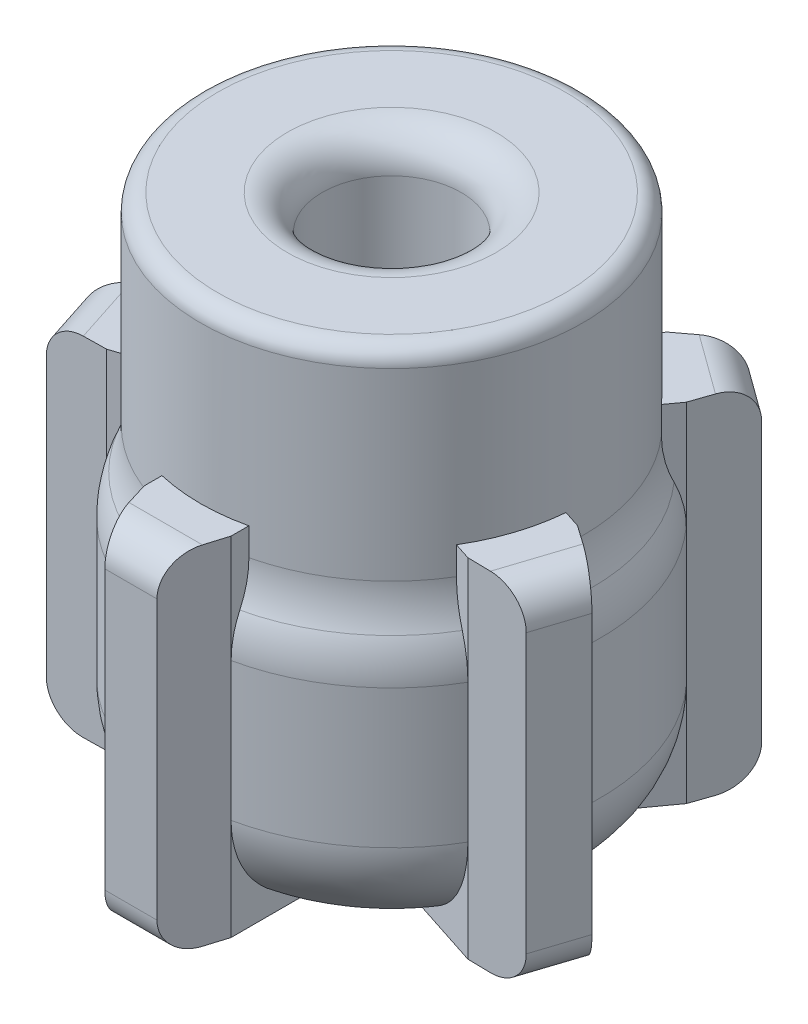
from build123d import *

# Parameters (mm, degrees)
SKETCH3_R           = 4
CUT_EXTRUDE2_DEPTH  = 29
FILLET2_R           = 2
BOSS_EXTRUDE1_DEPTH = 20
FILLET3_R           = 2


with BuildPart() as part:
    # Sketch1 → Revolve1 (revolve)
    with BuildSketch(Plane.XY):
        with BuildLine():
            Line((0, 30), (0, 0))
            Line((0, 0), (-6.164929537, 0))
            ThreePointArc((-6.164929537, 0), (-10.29094743, 1.70905257), (-12, 5.835070463))
            Line((-12, 5.835070463), (-12, 13.798025689))
            ThreePointArc((-12, 13.798025689), (-11.875902596, 14.955923247), (-11.50924738, 16.061224505))
            ThreePointArc((-11.50924738, 16.061224505), (-11.128774204, 17.208180724), (-11, 18.409715414))
            Line((-11, 18.409715414), (-11, 29))
            ThreePointArc((-11, 29), (-10.707106781, 29.707106781), (-10, 30))
            Line((-10, 30), (0, 30))
        make_face()
    revolve(axis=Axis((0, 30, 0), (0, -1, 0)))

    # Sketch3 → Cut-Extrude2 (cut)
    with BuildSketch(Plane(origin=(0, 30, 0), x_dir=(1, 0, 0), z_dir=(0, 1, 0))):
        Circle(SKETCH3_R)
    extrude(amount=-CUT_EXTRUDE2_DEPTH, mode=Mode.SUBTRACT)

    # Fillet2
    fillet2_edges = [part.edges().sort_by_distance(p)[0] for p in [
        (-4, 30, 0),
    ]]
    fillet(fillet2_edges, radius=FILLET2_R)

    # Sketch2 → Boss-Extrude1 (add)
    with BuildSketch(Plane.XZ):
        Polygon((-1.5, 15), (1.5, 15), (2.5, 11.736694594), (2.5, 5.635277828), (-2.5, 5.635277828), (-2.5, 11.736694594), align=None)
        Polygon((10.389717388, 6.004479378), (4.586925213, 4.119037908), (6.132010185, -0.636244674), (11.93480236, 1.249196797), (14.729373236, 3.208670141), (13.802322253, 6.06183969), align=None)
        Polygon((8.921198479, -8.025722254), (5.334875686, -3.0895724), (1.289790714, -6.028498661), (4.876113507, -10.964648515), (7.603253293, -13.016932794), (10.030304276, -11.253577037), align=None)
        Polygon((-4.876113507, -10.964648515), (-1.289790714, -6.028498661), (-5.334875686, -3.0895724), (-8.921198479, -8.025722254), (-10.030304276, -11.253577037), (-7.603253293, -13.016932794), align=None)
        Polygon((-11.93480236, 1.249196797), (-6.132010185, -0.636244674), (-4.586925213, 4.119037908), (-10.389717388, 6.004479378), (-13.802322253, 6.06183969), (-14.729373236, 3.208670141), align=None)
    extrude(amount=-BOSS_EXTRUDE1_DEPTH)

    # Fillet3
    fillet3_edges = [part.edges().sort_by_distance(p)[0] for p in [
        (-8.816778784, 20, -12.135254916),
        (-8.816778784, 0, -12.135254916),
        (-14.265847744, 20, 4.635254916),
        (-14.265847744, 0, 4.635254916),
        (0, 20, 15),
        (0, 0, 15),
        (14.265847744, 20, 4.635254916),
        (14.265847744, 0, 4.635254916),
        (8.816778784, 20, -12.135254916),
        (8.816778784, 0, -12.135254916),
    ]]
    fillet(fillet3_edges, radius=FILLET3_R)


solid = part.part
